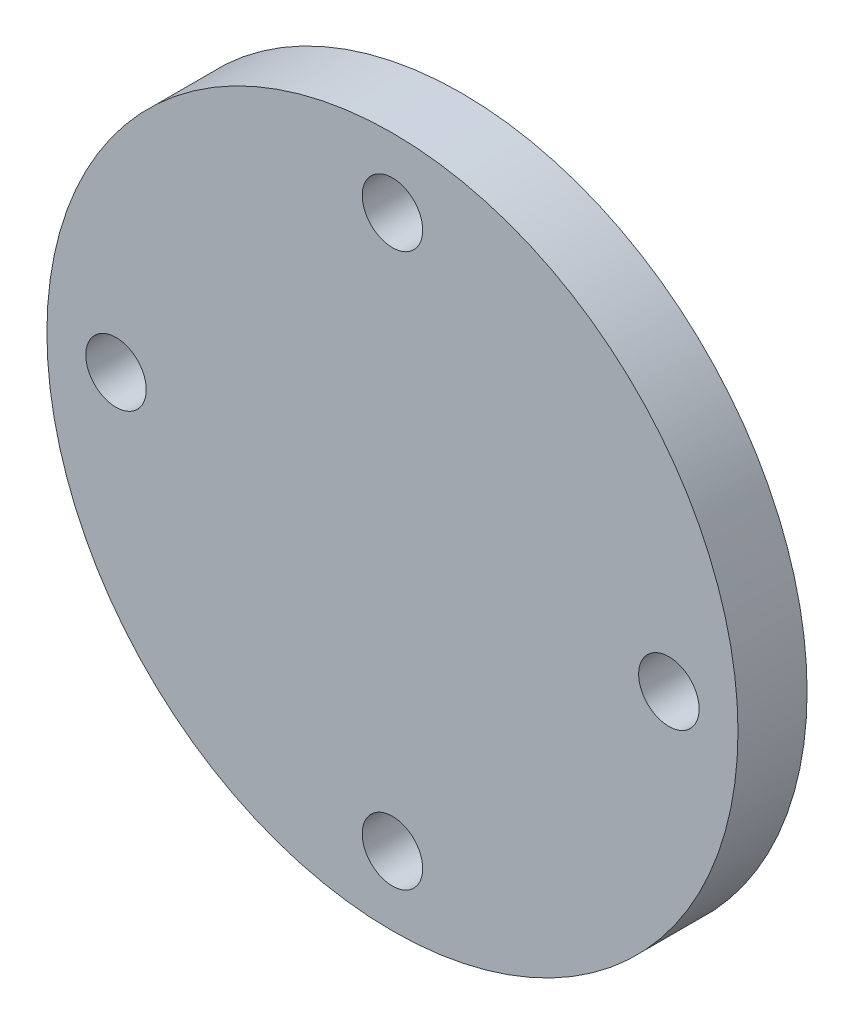
from build123d import *

# Parameters (mm, degrees)
SKETCH1_R           = 63.5
SKETCH1_R_2         = 5.55625
BOSS_EXTRUDE1_DEPTH = 12.7
SKETCH2_R           = 12.7
BOSS_EXTRUDE2_DEPTH = 35.56


with BuildPart() as part:
    # Sketch1 → Boss-Extrude1 (new body)
    with BuildSketch(Plane.XY):
        Circle(SKETCH1_R)
        with Locations((-50.8, 0)):
            Circle(SKETCH1_R_2, mode=Mode.SUBTRACT)
        with Locations((0, 50.8)):
            Circle(SKETCH1_R_2, mode=Mode.SUBTRACT)
        with Locations((50.8, 0)):
            Circle(SKETCH1_R_2, mode=Mode.SUBTRACT)
        with Locations((0, -50.8)):
            Circle(SKETCH1_R_2, mode=Mode.SUBTRACT)
    extrude(amount=BOSS_EXTRUDE1_DEPTH)

    # Sketch2 → Boss-Extrude2 (add)
    with BuildSketch(Plane(origin=(0, 0, 0), x_dir=(-1, 0, 0), z_dir=(0, 0, -1))):
        Circle(SKETCH2_R)
        with BuildLine():
            Line((-2.3876, 7.569892502), (-2.3876, 5.063801502))
            Line((-2.3876, 5.063801502), (2.3876, 5.063801502))
            Line((2.3876, 5.063801502), (2.3876, 7.569892502))
            ThreePointArc((2.3876, 7.569892502), (0, -7.9375), (-2.3876, 7.569892502))
        make_face(mode=Mode.SUBTRACT)
    extrude(amount=BOSS_EXTRUDE2_DEPTH)


solid = part.part
